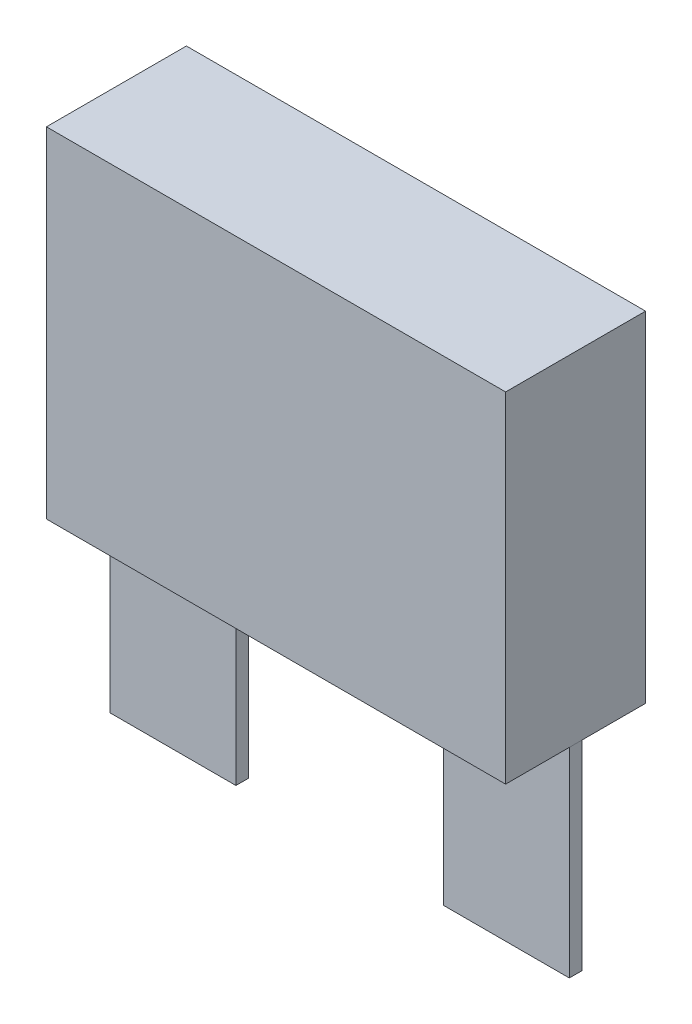
from build123d import *

# Parameters (mm, degrees)
SKETCH1_W             = 29.2
SKETCH1_H             = 8.9
BOSS_EXTRUDE1_DEPTH   = 21.6
SKETCH2_W             = 8
SKETCH2_H             = 0.8
BOSS_EXTRUDE2_DEPTH   = 12.7
BOSS_EXTRUDE2_2_DEPTH = 12.7


with BuildPart() as part:
    # Sketch1 → Boss-Extrude1 (new body)
    with BuildSketch(Plane(origin=(0, 0, 0), x_dir=(1, 0, 0), z_dir=(0, 1, 0))):
        Rectangle(SKETCH1_W, SKETCH1_H)
    extrude(amount=BOSS_EXTRUDE1_DEPTH)


with BuildPart() as body_2:
    # Sketch2 → Boss-Extrude2 (new body)
    with BuildSketch(Plane.XZ):
        with Locations((-10.6, 0)):
            Rectangle(SKETCH2_W, SKETCH2_H)
    extrude(amount=BOSS_EXTRUDE2_DEPTH)


with BuildPart() as body_3:
    # Sketch2 → Boss-Extrude2 2 (new body)
    with BuildSketch(Plane.XZ):
        with Locations((10.6, 0)):
            Rectangle(SKETCH2_W, SKETCH2_H)
    extrude(amount=BOSS_EXTRUDE2_2_DEPTH)


solid = Compound([part.part, body_2.part, body_3.part])
